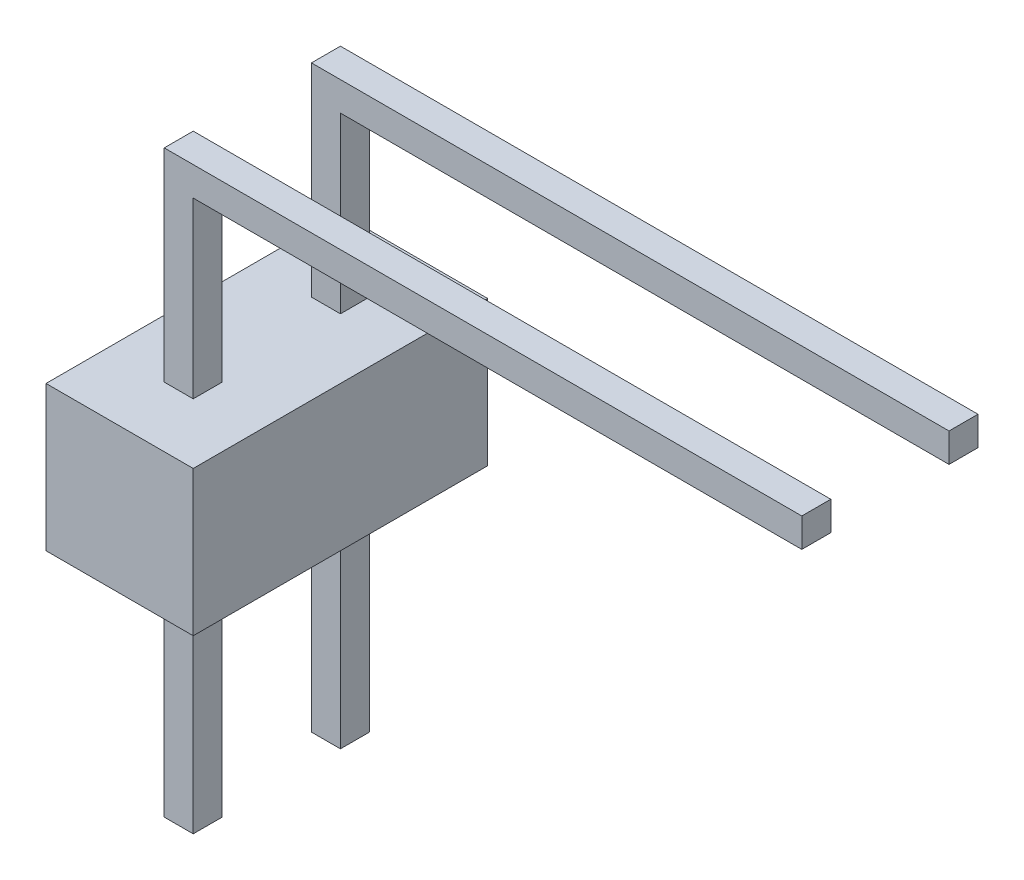
from build123d import *

# Parameters (mm, degrees)
BOSS_EXTRU_1_DEPTH         = 0.5
ESQUISSE2_W                = 2.54
ESQUISSE2_H                = 2.54
BOSS_EXTRU_2_DEPTH         = 2.5
R_P_TITION_LIN_AIRE3_COUNT = 2
R_P_TITION_LIN_AIRE3_PITCH = 2.54


with BuildPart() as part:
    # Esquisse1 → Boss.-Extru.1 (new body)
    with BuildSketch(Plane.XY):
        Polygon((0, -4), (0, 6), (11, 6), (11, 5.5), (0.5, 5.5), (0.5, -4), align=None)
    boss_extru_1 = extrude(amount=BOSS_EXTRU_1_DEPTH)

    # Esquisse2 → Boss.-Extru.2 (add)
    with BuildSketch(Plane(origin=(0, 0, 0), x_dir=(1, 0, 0), z_dir=(0, 1, 0))):
        with Locations((0.27, -0.27)):
            Rectangle(ESQUISSE2_W, ESQUISSE2_H)
    boss_extru_2 = extrude(amount=BOSS_EXTRU_2_DEPTH)

    # Répétition linéaire3: Boss.-Extru.1, Boss.-Extru.2 ×2
    with Locations(*[(0, 0, i * R_P_TITION_LIN_AIRE3_PITCH) for i in range(1, R_P_TITION_LIN_AIRE3_COUNT)]):
        add(boss_extru_1)
        add(boss_extru_2)


solid = part.part
